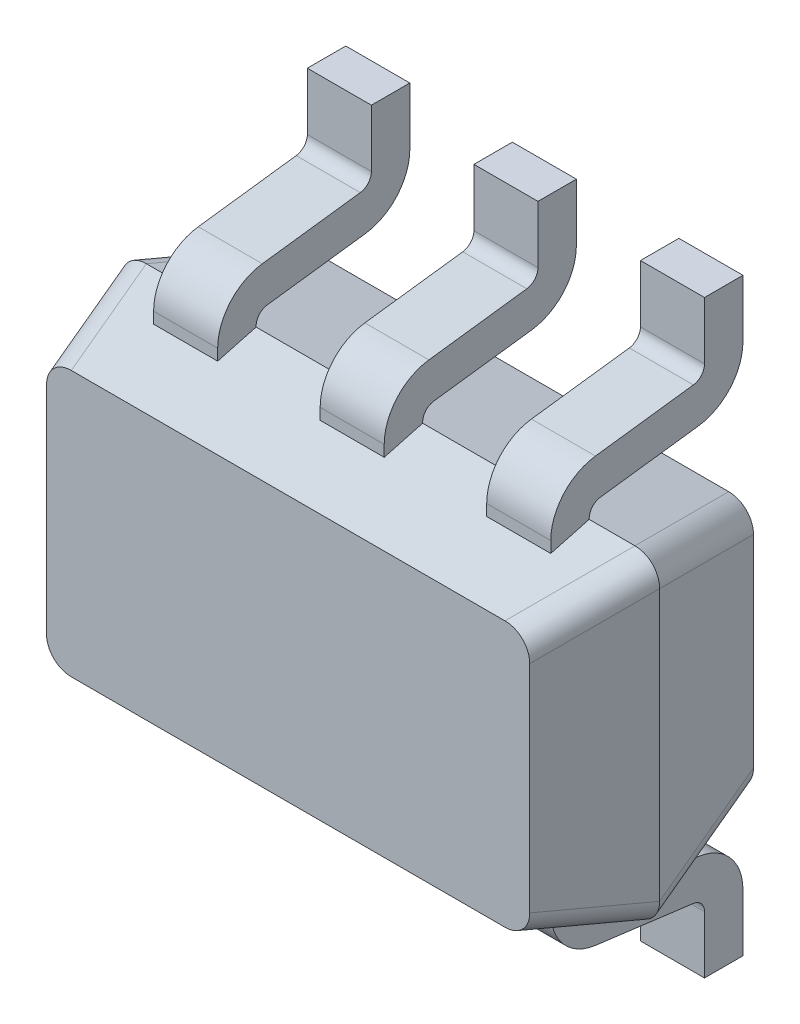
from build123d import *

# Parameters (mm, degrees)
EXTRUDE_START             = 0.6
SKETCH_1_W                = 2.1
SKETCH_1_H                = 1.25
EXTRUDE_1_DEPTH           = 0.4
EXTRUDE_1_TAPER           = 15
EXTRUDE_1_OTHER_WAY_DEPTH = 0.5
EXTRUDE_1_OTHER_WAY_TAPER = 15
EXTRUDE_START_2           = 0.65
EXTRUDE_4_DEPTH           = 0.125
EXTRUDE_5_DEPTH           = 0.125
PATTERN_LINEAR_2_COUNT    = 2
PATTERN_LINEAR_2_PITCH    = 1.3
PATTERN_LINEAR_3_COUNT    = 3
PATTERN_LINEAR_3_PITCH    = 0.65
FILLET_3_R                = 0.1


with BuildPart() as part:
    # Эскиз1 → Вытянуть1 (new body)
    with BuildSketch(Plane.XY.offset(EXTRUDE_START)):
        Rectangle(SKETCH_1_W, SKETCH_1_H)
    extrude(amount=EXTRUDE_1_DEPTH, taper=EXTRUDE_1_TAPER)

    # Эскиз1 → Вытянуть1 other way (add)
    with BuildSketch(Plane.XY.offset(EXTRUDE_START)):
        Rectangle(SKETCH_1_W, SKETCH_1_H)
    extrude(amount=-EXTRUDE_1_OTHER_WAY_DEPTH, taper=EXTRUDE_1_OTHER_WAY_TAPER)

    # Эскиз2 → Вытянуть4 (add, symmetric)
    with BuildSketch(Plane(origin=(0, 0, 0), x_dir=(0, 0, -1), z_dir=(1, 0, 0)).offset(EXTRUDE_START_2)):
        with BuildLine():
            Line((-0.6, 0.55), (-0.75, 0.55))
            Line((-0.75, 0.55), (-0.75, 0.628617172))
            ThreePointArc((-0.75, 0.628617172), (-0.700198025, 0.760679859), (-0.575594468, 0.82697272))
            Line((-0.575594468, 0.82697272), (-0.193601383, 0.876262542))
            ThreePointArc((-0.193601383, 0.876262542), (-0.162450494, 0.892835757), (-0.15, 0.925851429))
            Line((-0.15, 0.925851429), (-0.15, 1.15))
            Line((-0.15, 1.15), (0, 1.15))
            Line((0, 1.15), (0, 0.925851429))
            ThreePointArc((0, 0.925851429), (-0.049801975, 0.793788742), (-0.174405532, 0.727495881))
            Line((-0.174405532, 0.727495881), (-0.556398617, 0.678206059))
            ThreePointArc((-0.556398617, 0.678206059), (-0.587549506, 0.661632844), (-0.6, 0.628617172))
            Line((-0.6, 0.628617172), (-0.6, 0.55))
        make_face()
    extrude_4 = extrude(amount=EXTRUDE_4_DEPTH, both=True)

    # Эскиз2<4> → Вытянуть5 (add, symmetric)
    with BuildSketch(Plane(origin=(0, 0, 0), x_dir=(0, 0, -1), z_dir=(1, 0, 0)).offset(EXTRUDE_START_2)):
        with BuildLine():
            ThreePointArc((-0.6, -0.628617172), (-0.587549506, -0.661632844), (-0.556398617, -0.678206059))
            Line((-0.556398617, -0.678206059), (-0.174405532, -0.727495881))
            ThreePointArc((-0.174405532, -0.727495881), (-0.049801975, -0.793788742), (0, -0.925851429))
            Line((0, -0.925851429), (0, -1.15))
            Line((0, -1.15), (-0.15, -1.15))
            Line((-0.15, -1.15), (-0.15, -0.925851429))
            ThreePointArc((-0.15, -0.925851429), (-0.162450494, -0.892835757), (-0.193601383, -0.876262542))
            Line((-0.193601383, -0.876262542), (-0.575594468, -0.82697272))
            ThreePointArc((-0.575594468, -0.82697272), (-0.700198025, -0.760679859), (-0.75, -0.628617172))
            Line((-0.75, -0.628617172), (-0.75, -0.55))
            Line((-0.75, -0.55), (-0.6, -0.55))
            Line((-0.6, -0.55), (-0.6, -0.628617172))
        make_face()
    extrude_5 = extrude(amount=EXTRUDE_5_DEPTH, both=True)

    # Линейный массив2: Вытянуть5 ×2
    with Locations(*[(-i * PATTERN_LINEAR_2_PITCH, 0, 0) for i in range(1, PATTERN_LINEAR_2_COUNT)]):
        add(extrude_5)

    # Линейный массив3: Вытянуть4 ×3
    with Locations(*[(-i * PATTERN_LINEAR_3_PITCH, 0, 0) for i in range(1, PATTERN_LINEAR_3_COUNT)]):
        add(extrude_4)

    # Скругление3
    fillet_3_edges = [part.edges().sort_by_distance(p)[0] for p in [
        (0.996410162, -0.571410162, 0.8),
        (0.996410162, 0.571410162, 0.8),
        (-0.996410162, 0.571410162, 0.8),
        (-0.996410162, -0.571410162, 0.8),
        (0.983012702, -0.558012702, 0.35),
        (-0.983012702, -0.558012702, 0.35),
        (-0.983012702, 0.558012702, 0.35),
        (0.983012702, 0.558012702, 0.35),
    ]]
    fillet(fillet_3_edges, radius=FILLET_3_R)


solid = part.part
